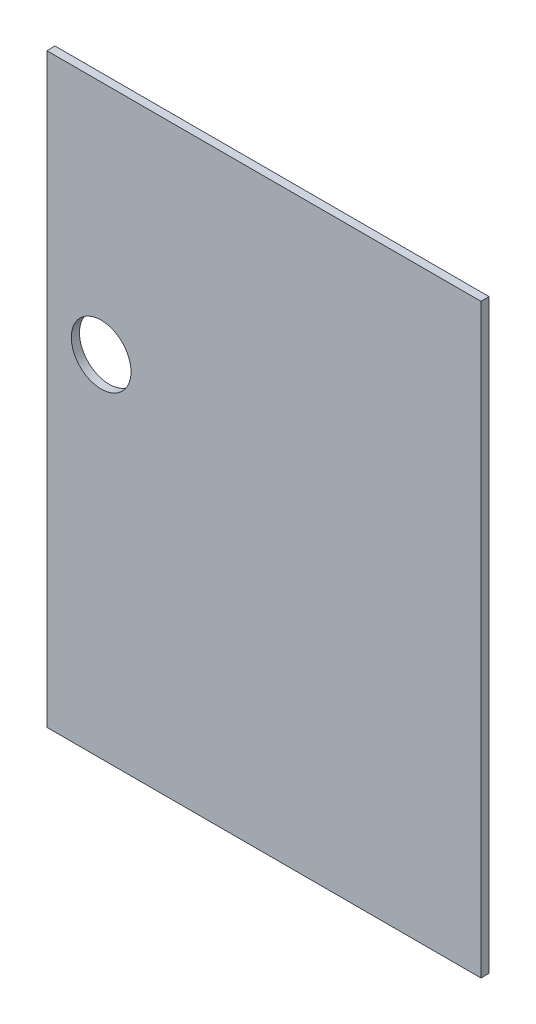
from build123d import *

# Parameters (mm, degrees)
SKETCH1_W           = 160
SKETCH1_H           = 216
BOSS_EXTRUDE1_DEPTH = 3
SKETCH2_R           = 11
CUT_EXTRUDE1_DEPTH  = 3


with BuildPart() as part:
    # Sketch1 → Boss-Extrude1 (new body)
    with BuildSketch(Plane.XY):
        with Locations((80, 108)):
            Rectangle(SKETCH1_W, SKETCH1_H)
    extrude(amount=BOSS_EXTRUDE1_DEPTH)

    # Sketch2 → Cut-Extrude1 (cut)
    with BuildSketch(Plane.XY.offset(3)):
        with Locations((20, 129)):
            Circle(SKETCH2_R)
    extrude(amount=-CUT_EXTRUDE1_DEPTH, mode=Mode.SUBTRACT)


solid = part.part
